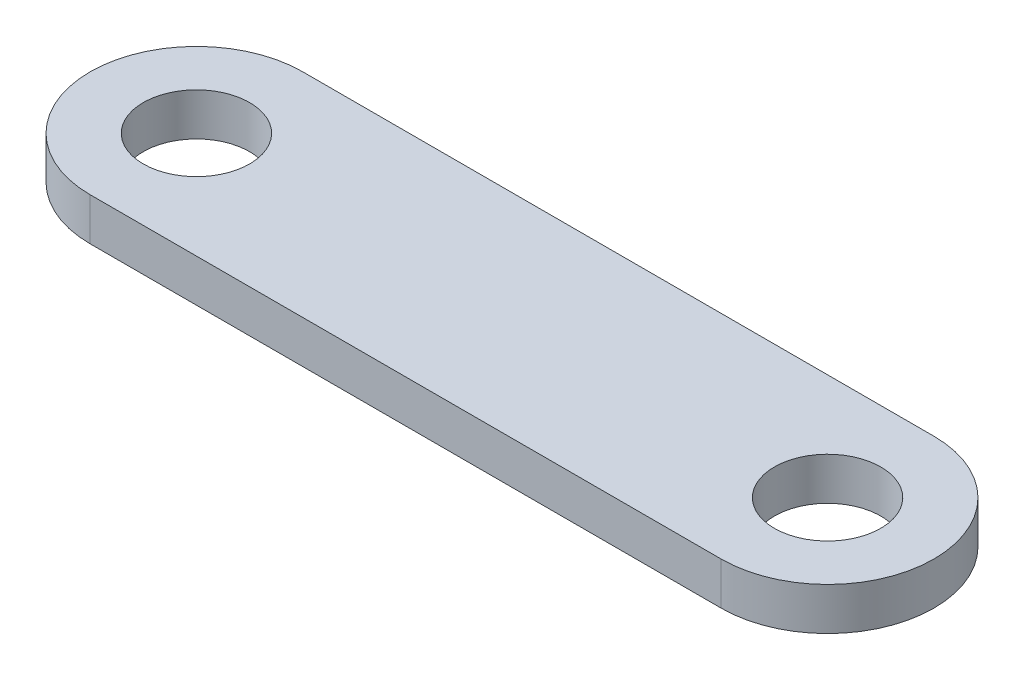
from build123d import *

# Parameters (mm, degrees)
SKETCH1_R           = 3.175
BOSS_EXTRUDE1_DEPTH = 2.54


with BuildPart() as part:
    # Sketch1 → Boss-Extrude1 (new body)
    with BuildSketch(Plane(origin=(0, 0, 0), x_dir=(1, 0, 0), z_dir=(0, 1, 0))):
        with BuildLine():
            Line((-18.837656, 6.35), (18.837656, 6.35))
            ThreePointArc((18.837656, 6.35), (25.187656, 0), (18.837656, -6.35))
            Line((18.837656, -6.35), (-18.837656, -6.35))
            ThreePointArc((-18.837656, -6.35), (-25.187656, 0), (-18.837656, 6.35))
        make_face()
        with Locations((-18.837656, 0)):
            Circle(SKETCH1_R, mode=Mode.SUBTRACT)
        with Locations((18.837656, 0)):
            Circle(SKETCH1_R, mode=Mode.SUBTRACT)
    extrude(amount=BOSS_EXTRUDE1_DEPTH)


solid = part.part
